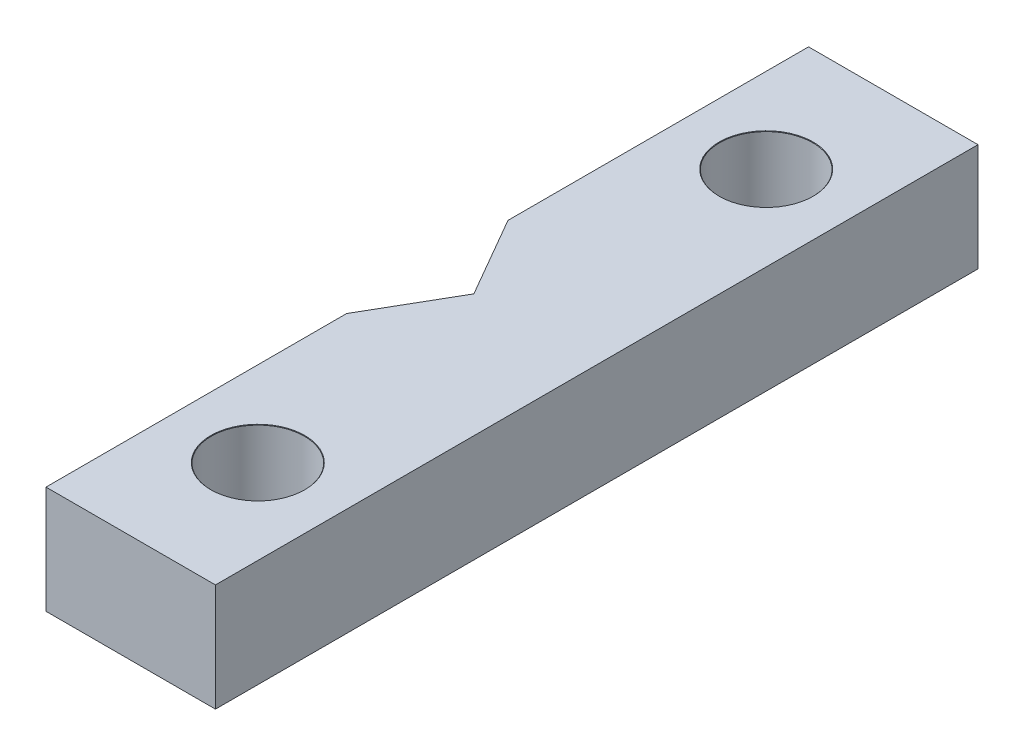
from build123d import *

# Parameters (mm, degrees)
BOSS_EXTRUDE1_DEPTH            = 6.35
M5_CLEARANCE_HOLE2_D           = 5.5
M5_CLEARANCE_HOLE2_DEPTH       = 10.1
M5_CLEARANCE_HOLE2_CSINK_D     = 5.55
M5_CLEARANCE_HOLE2_CSINK_ANGLE = 90
M5_CLEARANCE_HOLE2_TIP         = 1.652366702


with BuildPart() as part:
    # Sketch1 → Boss-Extrude1 (new body)
    with BuildSketch(Plane(origin=(0, 0, 0), x_dir=(1, 0, 0), z_dir=(0, 1, 0))):
        Polygon((10.749371316, 22.5), (0.749371316, 22.5), (0.749371316, 4.762050808), (3.498742631, 0), (0.749371316, -4.762050808), (0.749371316, -22.5), (10.749371316, -22.5), align=None)
    extrude(amount=BOSS_EXTRUDE1_DEPTH)

    # M5 Clearance Hole2
    with Locations(Plane(origin=(0, 6.35, 0), x_dir=(1, 0, 0), z_dir=(0, 1, 0))):
        with Locations((5.749371316, 15), (5.749371316, -15)):
            CounterSinkHole(M5_CLEARANCE_HOLE2_D / 2, M5_CLEARANCE_HOLE2_CSINK_D / 2, depth=M5_CLEARANCE_HOLE2_DEPTH, counter_sink_angle=M5_CLEARANCE_HOLE2_CSINK_ANGLE)
            with Locations((0, 0, -(M5_CLEARANCE_HOLE2_DEPTH + M5_CLEARANCE_HOLE2_TIP / 2))):  # 118° drill point
                Cone(0, M5_CLEARANCE_HOLE2_D / 2, M5_CLEARANCE_HOLE2_TIP, mode=Mode.SUBTRACT)


solid = part.part
